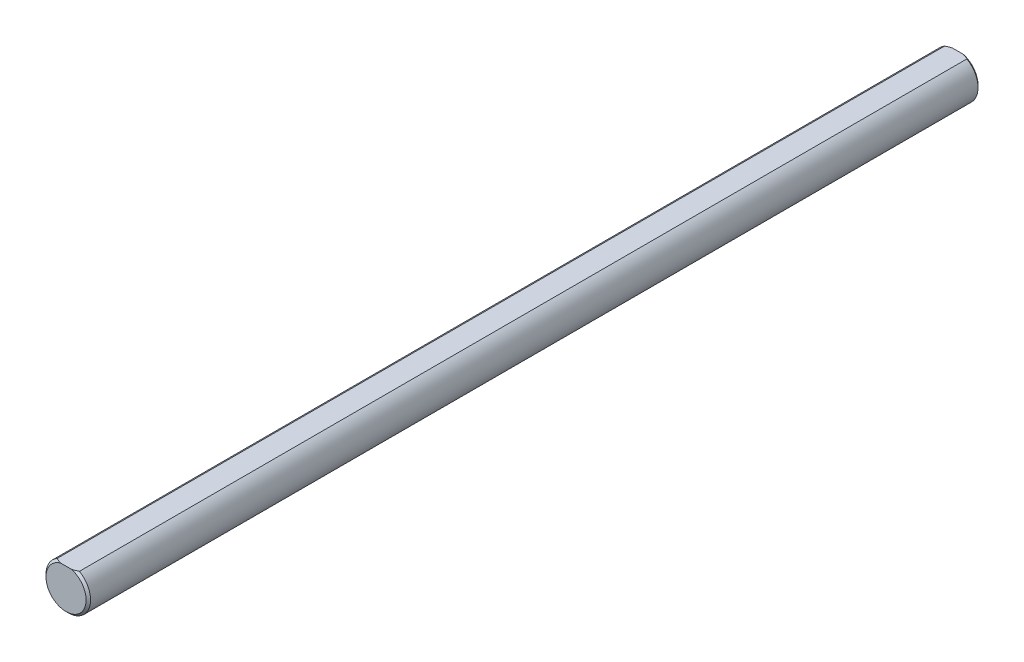
from build123d import *

# Parameters (mm, degrees)
SKETCH3_R                = 5
BOSS_EXTRUDE2_DEPTH      = 100
BOSS_EXTRUDE2_DEPTH_BACK = 100
CUT_EXTRUDE5_DEPTH       = 101
CUT_EXTRUDE5_DEPTH_BACK  = 101
CHAMFER1_SIZE            = 0.5


with BuildPart() as part:
    # Sketch3 → Boss-Extrude2 (new body, two sides)
    with BuildSketch(Plane.XY) as boss_extrude2_sk:
        Circle(SKETCH3_R)
    extrude(amount=BOSS_EXTRUDE2_DEPTH)
    extrude(boss_extrude2_sk.sketch, amount=-BOSS_EXTRUDE2_DEPTH_BACK)

    # Sketch10 → Cut-Extrude5 (cut, two sides)
    with BuildSketch(Plane.XY) as cut_extrude5_sk:
        with BuildLine():
            Line((-2.5, 4.330127019), (2.5, 4.330127019))
            ThreePointArc((2.5, 4.330127019), (0, 5), (-2.5, 4.330127019))
        make_face()
    extrude(amount=CUT_EXTRUDE5_DEPTH, mode=Mode.SUBTRACT)
    extrude(cut_extrude5_sk.sketch, amount=-CUT_EXTRUDE5_DEPTH_BACK, mode=Mode.SUBTRACT)

    # Chamfer1
    chamfer1_edges = [part.edges().sort_by_distance(p)[0] for p in [
        (0, -5, -100),
        (0, -5, 100),
    ]]
    chamfer(chamfer1_edges, length=CHAMFER1_SIZE)


solid = part.part
